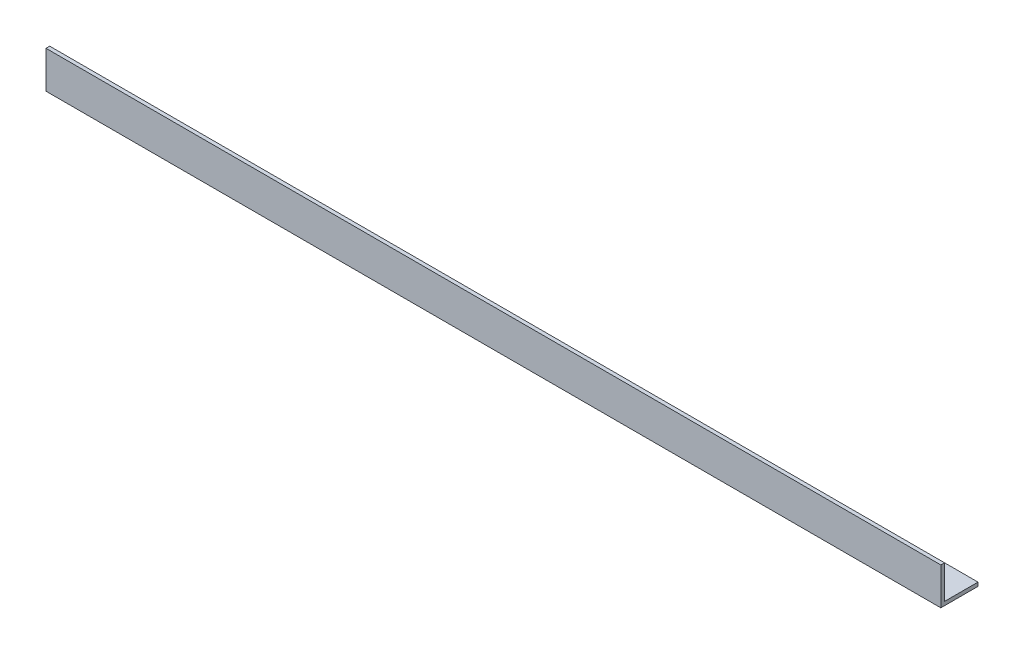
from build123d import *

# Parameters (mm, degrees)
EXTRUDE_1_DEPTH = 361


with BuildPart() as part:
    # Эскиз1 → Бобышка-Вытянуть1 (new body)
    with BuildSketch(Plane(origin=(0, 0, 0), x_dir=(0, 0, -1), z_dir=(1, 0, 0))):
        Polygon((0, 0), (0, 15), (1.5, 15), (1.5, 1.5), (15, 1.5), (15, 0), align=None)
    extrude(amount=EXTRUDE_1_DEPTH)


solid = part.part
